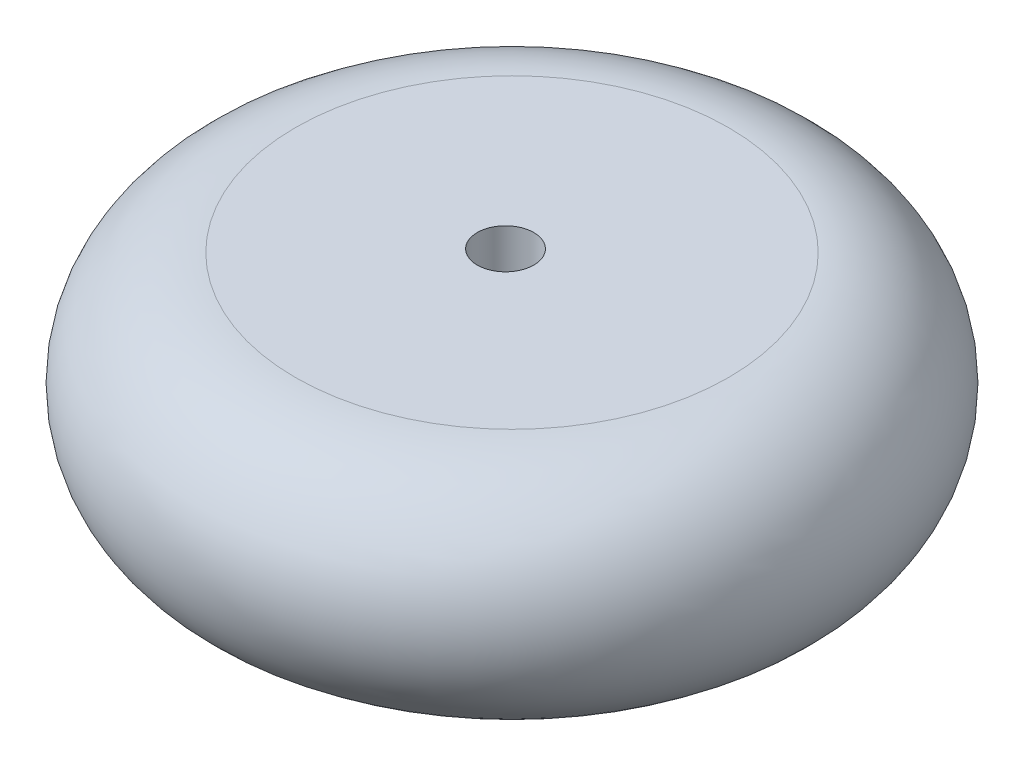
from build123d import *

# Parameters (mm, degrees)
CUT_EXTRUDE_1_REACH = 26
SKETCH_2_R          = 3


with BuildPart() as part:
    # 草图1 → 旋转1 (revolve)
    with BuildSketch(Plane.XY):
        with BuildLine():
            Line((-10, 12), (13, 12))
            Line((13, 12), (13, -12))
            Line((13, -12), (-10, -12))
            ThreePointArc((-10, -12), (-22, 0), (-10, 12))
        make_face()
    revolve(axis=Axis((13, 12, 0), (0, -1, 0)))

    # 草图2 → 切除-拉伸1 (cut, up to next)
    with BuildSketch(Plane.XZ.offset(12), mode=Mode.PRIVATE) as cut_extrude_1_sk1:
        with Locations((12.310855645, 0)):
            Circle(SKETCH_2_R)
    cut_extrude_1_tool1 = extrude(cut_extrude_1_sk1.sketch, amount=-CUT_EXTRUDE_1_REACH, mode=Mode.PRIVATE) & part.part
    add(cut_extrude_1_tool1.solids().sort_by_distance((12.310856, -12, 0))[0], mode=Mode.SUBTRACT)


solid = part.part
